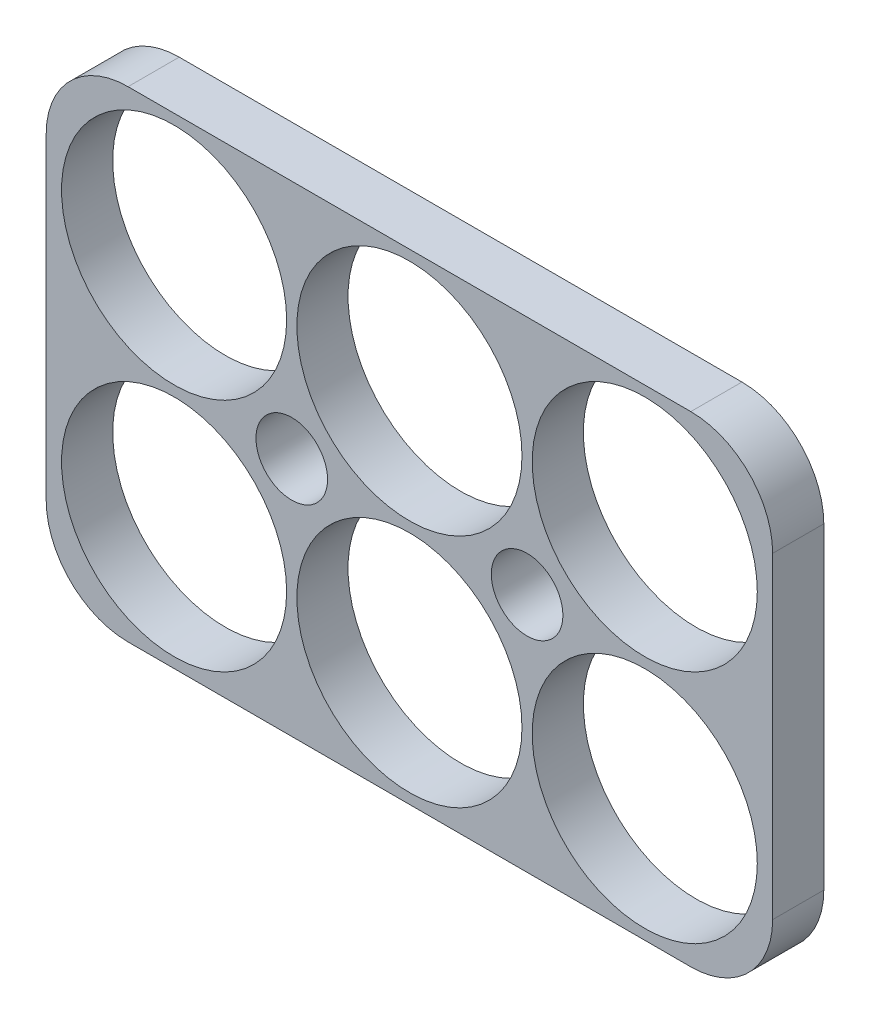
from build123d import *

# Parameters (mm, degrees)
SKETCH_1_W      = 71
SKETCH_1_H      = 47
SKETCH_1_R      = 11
SKETCH_1_R_2    = 3.5
EXTRUDE_2_DEPTH = 5
FILLET_1_R      = 8


with BuildPart() as part:
    # 草图1 → 凸台-拉伸2 (new body)
    with BuildSketch(Plane.XY):
        Rectangle(SKETCH_1_W, SKETCH_1_H)
        with Locations((-23, 11.5)):
            Circle(SKETCH_1_R, mode=Mode.SUBTRACT)
        with Locations((0, 11.5)):
            Circle(SKETCH_1_R, mode=Mode.SUBTRACT)
        with Locations((23, 11.5)):
            Circle(SKETCH_1_R, mode=Mode.SUBTRACT)
        with Locations((23, -11.5)):
            Circle(SKETCH_1_R, mode=Mode.SUBTRACT)
        with Locations((0, -11.5)):
            Circle(SKETCH_1_R, mode=Mode.SUBTRACT)
        with Locations((-23, -11.5)):
            Circle(SKETCH_1_R, mode=Mode.SUBTRACT)
        with Locations((11.5, 0)):
            Circle(SKETCH_1_R_2, mode=Mode.SUBTRACT)
        with Locations((-11.5, 0)):
            Circle(SKETCH_1_R_2, mode=Mode.SUBTRACT)
    extrude(amount=-EXTRUDE_2_DEPTH)

    # 圆角1
    fillet_1_edges = [part.edges().sort_by_distance(p)[0] for p in [
        (35.5, -23.5, -2.5),
        (-35.5, -23.5, -2.5),
        (-35.5, 23.5, -2.5),
        (35.5, 23.5, -2.5),
    ]]
    fillet(fillet_1_edges, radius=FILLET_1_R)


solid = part.part
